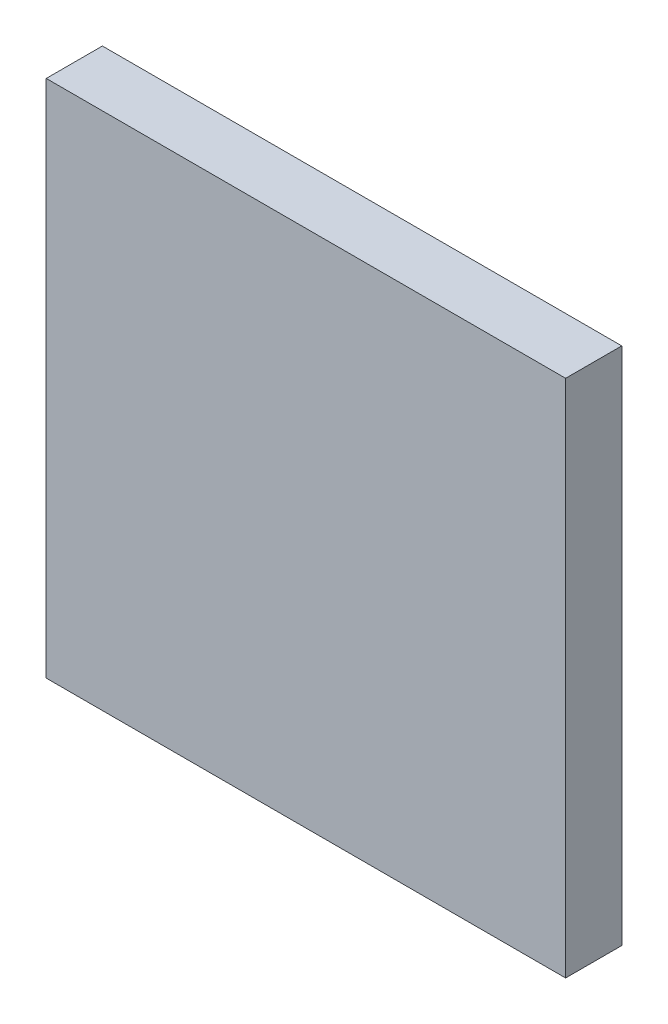
from build123d import *

# Parameters (mm, degrees)
ESBO_O1_W                = 37
ESBO_O1_H                = 37
RESSALTO_EXTRUS_O1_DEPTH = 4


with BuildPart() as part:
    # Esboço1 → Ressalto-extrusão1 (new body)
    with BuildSketch(Plane.XY):
        with Locations((11.605919231, -2.18145072)):
            Rectangle(ESBO_O1_W, ESBO_O1_H)
    extrude(amount=RESSALTO_EXTRUS_O1_DEPTH)


solid = part.part
